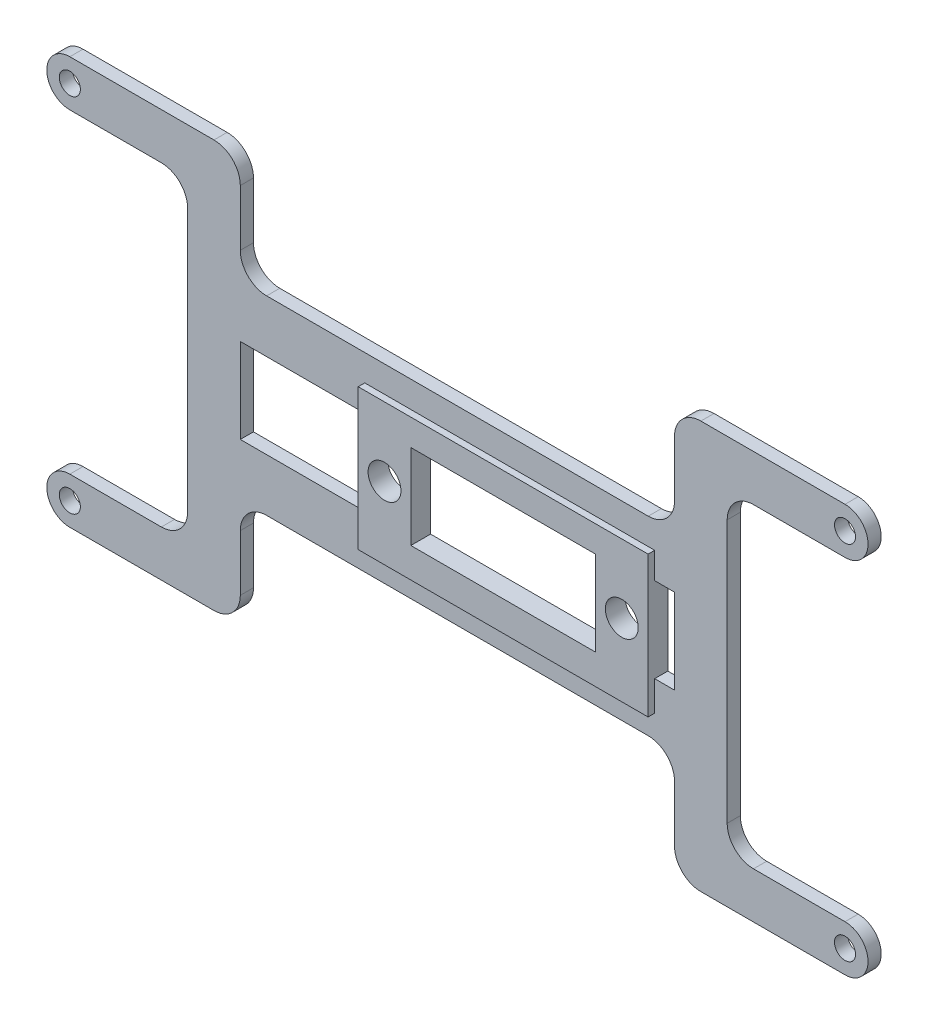
from build123d import *

# Parameters (mm, degrees)
SKETCH1_R            = 1.6
SKETCH1_R_2          = 2.1
BOSS_EXTRUDE3_DEPTH  = 2
BOSS_EXTRUDE4_DEPTH  = 2
SKETCH4_W            = 66
SKETCH4_H            = 16.340111315
SKETCH4_H_2          = 24.741581589
CUT_EXTRUDE3_DEPTH   = 14.5
FILLET1_R            = 4
SKETCH5_W            = 26
SKETCH5_H            = 27
SKETCH5_R            = 6
BOSS_EXTRUDE5_DEPTH  = 2
SKETCH6_W            = 5
SKETCH6_H            = 27
CUT_EXTRUDE4_DEPTH   = 14.5
SKETCH7_R            = 2.5
BOSS_EXTRUDE6_DEPTH  = 2
SKETCH8_R            = 2.5
CUT_EXTRUDE5_DEPTH   = 10
SKETCH9_W            = 22.081
SKETCH9_H            = 27
CUT_EXTRUDE6_DEPTH   = 10
CUT_EXTRUDE7_DEPTH   = 10
SKETCH11_W           = 28.061
SKETCH11_H           = 7.05
BOSS_EXTRUDE7_DEPTH  = 2
SKETCH12_W           = 44.061
SKETCH12_H           = 28.9
CUT_EXTRUDE9_DEPTH   = 10
BOSS_EXTRUDE9_DEPTH  = 2
FILLET2_R            = 4
SKETCH14_R           = 2.5
SKETCH14_W           = 28.061
SKETCH14_H           = 12.9
BOSS_EXTRUDE10_DEPTH = 1


with BuildPart() as part:
    # Sketch1 → Boss-Extrude3 (new body)
    with BuildSketch(Plane.XY):
        with BuildLine():
            Line((0, 3.5), (37.911912125, 3.5))
            Line((37.911912125, 3.5), (37.911912125, 13.97107578))
            Line((37.911912125, 13.97107578), (37.911912125, 40.97107578))
            Line((37.911912125, 40.97107578), (37.911912125, 51.44215156))
            Line((37.911912125, 51.44215156), (0, 51.44215156))
            ThreePointArc((0, 51.44215156), (-3.5, 54.94215156), (0, 58.44215156))
            Line((0, 58.44215156), (45.911912125, 58.44215156))
            Line((45.911912125, 58.44215156), (45.911912125, 51.44215156))
            Line((45.911912125, 51.44215156), (45.911912125, 48.97107578))
            Line((45.911912125, 48.97107578), (50.911912125, 48.97107578))
            Line((50.911912125, 48.97107578), (66.911912125, 48.97107578))
            Line((66.911912125, 48.97107578), (71.911912125, 48.97107578))
            Line((71.911912125, 48.97107578), (71.911912125, 51.44215156))
            Line((71.911912125, 51.44215156), (71.911912125, 58.44215156))
            Line((71.911912125, 58.44215156), (117.82382425, 58.44215156))
            ThreePointArc((117.82382425, 58.44215156), (121.32382425, 54.94215156), (117.82382425, 51.44215156))
            Line((117.82382425, 51.44215156), (79.911912125, 51.44215156))
            Line((79.911912125, 51.44215156), (79.911912125, 40.97107578))
            Line((79.911912125, 40.97107578), (79.911912125, 13.97107578))
            Line((79.911912125, 13.97107578), (79.911912125, 3.5))
            Line((79.911912125, 3.5), (117.82382425, 3.5))
            ThreePointArc((117.82382425, 3.5), (121.32382425, 0), (117.82382425, -3.5))
            Line((117.82382425, -3.5), (71.911912125, -3.5))
            Line((71.911912125, -3.5), (71.911912125, 3.5))
            Line((71.911912125, 3.5), (71.911912125, 5.97107578))
            Line((71.911912125, 5.97107578), (66.911912125, 5.97107578))
            Line((66.911912125, 5.97107578), (50.911912125, 5.97107578))
            Line((50.911912125, 5.97107578), (45.911912125, 5.97107578))
            Line((45.911912125, 5.97107578), (45.911912125, 3.5))
            Line((45.911912125, 3.5), (45.911912125, -3.5))
            Line((45.911912125, -3.5), (0, -3.5))
            ThreePointArc((0, -3.5), (-3.5, 0), (0, 3.5))
        make_face()
        with Locations((0, 54.94215156)):
            Circle(SKETCH1_R, mode=Mode.SUBTRACT)
        with Locations((117.82382425, 54.94215156)):
            Circle(SKETCH1_R, mode=Mode.SUBTRACT)
        with Locations((117.82382425, 0)):
            Circle(SKETCH1_R, mode=Mode.SUBTRACT)
        Circle(SKETCH1_R, mode=Mode.SUBTRACT)
        with Locations((66.911912125, 44.97107578)):
            Circle(SKETCH1_R_2, mode=Mode.SUBTRACT)
        with Locations((66.911912125, 9.97107578)):
            Circle(SKETCH1_R_2, mode=Mode.SUBTRACT)
        with Locations((50.911912125, 9.97107578)):
            Circle(SKETCH1_R_2, mode=Mode.SUBTRACT)
        with Locations((50.911912125, 44.97107578)):
            Circle(SKETCH1_R_2, mode=Mode.SUBTRACT)
        Polygon((66.911912125, 40.97107578), (50.911912125, 40.97107578), (45.911912125, 40.97107578), (45.911912125, 27.47107578), (45.911912125, 13.97107578), (50.911912125, 13.97107578), (66.911912125, 13.97107578), (71.911912125, 13.97107578), (71.911912125, 27.47107578), (71.911912125, 40.97107578), align=None, mode=Mode.SUBTRACT)
    extrude(amount=BOSS_EXTRUDE3_DEPTH)

    # Sketch3 → Boss-Extrude4 (add)
    with BuildSketch(Plane.XY.offset(2)):
        Polygon((71.911912125, 13.97107578), (99.911912125, 13.97107578), (99.911912125, 3.5), (91.911912125, 3.5), (91.911912125, 5.97107578), (71.911912125, 5.97107578), align=None)
        Polygon((91.911912125, 51.44215156), (99.911912125, 51.44215156), (99.911912125, 40.97107578), (71.911912125, 40.97107578), (71.911912125, 48.97107578), (91.911912125, 48.97107578), align=None)
        Polygon((45.911912125, 40.97107578), (17.911912125, 40.97107578), (17.911912125, 51.44215156), (25.911912125, 51.44215156), (25.911912125, 48.97107578), (45.911912125, 48.97107578), align=None)
        Polygon((25.911912125, 3.5), (17.911912125, 3.5), (17.911912125, 13.97107578), (45.911912125, 13.97107578), (45.911912125, 5.97107578), (25.911912125, 5.97107578), align=None)
    extrude(amount=-BOSS_EXTRUDE4_DEPTH)

    # Sketch4 → Cut-Extrude3 (cut)
    with BuildSketch(Plane.XY.offset(2)):
        with Locations((58.911912125, 57.141131438)):
            Rectangle(SKETCH4_W, SKETCH4_H)
        with Locations((58.911912125, -6.399715014)):
            Rectangle(SKETCH4_W, SKETCH4_H_2)
    extrude(amount=-CUT_EXTRUDE3_DEPTH, mode=Mode.SUBTRACT)

    # Fillet1
    fillet1_edges = [part.edges().sort_by_distance(p)[0] for p in [
        (99.911912125, 13.97107578, 1),
        (99.911912125, 3.5, 1),
        (91.911912125, 5.97107578, 1),
        (91.911912125, 48.97107578, 1),
        (99.911912125, 51.44215156, 1),
        (99.911912125, 40.97107578, 1),
        (17.911912125, 40.97107578, 1),
        (17.911912125, 51.44215156, 1),
        (25.911912125, 48.97107578, 1),
        (25.911912125, 5.97107578, 1),
        (17.911912125, 3.5, 1),
        (17.911912125, 13.97107578, 1),
        (91.911912125, 58.44215156, 1),
        (25.911912125, 58.44215156, 1),
        (91.911912125, -3.5, 1),
        (25.911912125, -3.5, 1),
    ]]
    fillet(fillet1_edges, radius=FILLET1_R)

    # Sketch5 → Boss-Extrude5 (add)
    with BuildSketch(Plane.XY.offset(2)):
        with Locations((58.911912125, 27.47107578)):
            Rectangle(SKETCH5_W, SKETCH5_H)
        with Locations((58.911912125, 27.47107578)):
            Circle(SKETCH5_R, mode=Mode.SUBTRACT)
    extrude(amount=-BOSS_EXTRUDE5_DEPTH)

    # Sketch6 → Cut-Extrude4 (cut)
    with BuildSketch(Plane.XY.offset(2)):
        with Locations((40.411912125, 27.47107578)):
            Rectangle(SKETCH6_W, SKETCH6_H)
        with Locations((77.411912125, 27.47107578)):
            Rectangle(SKETCH6_W, SKETCH6_H)
    extrude(amount=-CUT_EXTRUDE4_DEPTH, mode=Mode.SUBTRACT)

    # Sketch7 → Boss-Extrude6 (add)
    with BuildSketch(Plane.XY.offset(2)):
        Polygon((80.891912125, 27.47107578), (80.891912125, 40.97107578), (88.891912125, 40.97107578), (88.891912125, 27.47107578), (88.891912125, 13.97107578), (80.891912125, 13.97107578), align=None)
        with Locations((84.891912125, 27.47107578)):
            Circle(SKETCH7_R, mode=Mode.SUBTRACT)
    extrude(amount=-BOSS_EXTRUDE6_DEPTH)

    # Sketch8 → Cut-Extrude5 (cut)
    with BuildSketch(Plane.XY.offset(2)):
        with Locations((48.830912125, 27.47107578)):
            Circle(SKETCH8_R)
    extrude(amount=-CUT_EXTRUDE5_DEPTH, mode=Mode.SUBTRACT)

    # Sketch9 → Cut-Extrude6 (cut)
    with BuildSketch(Plane.XY.offset(2)):
        Polygon((42.911912125, 40.97107578), (44.830912125, 40.97107578), (44.830912125, 27.47107578), (44.830912125, 13.97107578), (42.911912125, 13.97107578), align=None)
        with Locations((63.871412125, 27.47107578)):
            Rectangle(SKETCH9_W, SKETCH9_H)
    extrude(amount=-CUT_EXTRUDE6_DEPTH, mode=Mode.SUBTRACT)

    # Sketch10 → Cut-Extrude7 (cut)
    with BuildSketch(Plane.XY.offset(2)):
        Polygon((44.830912125, 13.97107578), (44.830912125, 13.02107578), (88.891912125, 13.02107578), (88.891912125, 13.97107578), (106.020559472, 13.97107578), (106.020559472, 3.5), (12.964535502, 3.5), (12.964535502, 13.97107578), align=None)
        Polygon((88.891912125, 40.97107578), (88.891912125, 41.92107578), (44.830912125, 41.92107578), (44.830912125, 40.97107578), (12.964535502, 40.97107578), (12.964535502, 51.44215156), (106.020559472, 51.44215156), (106.020559472, 40.97107578), align=None)
    extrude(amount=-CUT_EXTRUDE7_DEPTH, mode=Mode.SUBTRACT)

    # Sketch11 → Boss-Extrude7 (add)
    with BuildSketch(Plane.XY.offset(2)):
        with Locations((66.861412125, 37.44607578)):
            Rectangle(SKETCH11_W, SKETCH11_H)
        with Locations((66.861412125, 17.49607578)):
            Rectangle(SKETCH11_W, SKETCH11_H)
    extrude(amount=-BOSS_EXTRUDE7_DEPTH)

    # Sketch12 → Cut-Extrude9 (cut)
    with BuildSketch(Plane.XY.offset(2)):
        Polygon((25.911912125, 1.23553789), (25.911912125, 54.44215156), (91.911912125, 54.44215156), (91.911912125, 0.5), align=None)
        with Locations((66.861412125, 27.47107578)):
            Rectangle(SKETCH12_W, SKETCH12_H, mode=Mode.SUBTRACT)
    extrude(amount=-CUT_EXTRUDE9_DEPTH, mode=Mode.SUBTRACT)

    # Sketch13 → Boss-Extrude9 (add)
    with BuildSketch(Plane.XY.offset(2)):
        Polygon((17.911912125, 3.5), (25.911912125, 3.5), (25.911912125, 13.02107578), (44.830912125, 13.02107578), (44.830912125, 21.02107578), (25.911912125, 21.02107578), (25.911912125, 33.92107578), (44.830912125, 33.92107578), (44.830912125, 41.92107578), (25.911912125, 41.92107578), (25.911912125, 51.44215156), (17.911912125, 51.44215156), (17.911912125, 13.02107578), align=None)
        Polygon((99.911912125, 51.44215156), (91.911912125, 51.44215156), (91.911912125, 41.92107578), (88.891912125, 41.92107578), (88.891912125, 33.92107578), (91.911912125, 33.92107578), (91.911912125, 21.02107578), (88.891912125, 21.02107578), (88.891912125, 13.02107578), (91.911912125, 13.02107578), (91.911912125, 3.5), (99.911912125, 3.5), (99.911912125, 41.92107578), align=None)
    extrude(amount=-BOSS_EXTRUDE9_DEPTH)

    # Fillet2
    fillet2_edges = [part.edges().sort_by_distance(p)[0] for p in [
        (99.911912125, 51.44215156, 1),
        (99.911912125, 3.5, 1),
        (91.911912125, 13.02107578, 1),
        (91.911912125, 41.92107578, 1),
        (25.911912125, 13.02107578, 1),
        (17.911912125, 3.5, 1),
        (17.911912125, 51.44215156, 1),
        (25.911912125, 41.92107578, 1),
    ]]
    fillet(fillet2_edges, radius=FILLET2_R)

    # Sketch14 → Boss-Extrude10 (add)
    with BuildSketch(Plane.XY.offset(2)):
        Polygon((44.830912125, 33.92107578), (44.830912125, 37.92107578), (88.891912125, 37.92107578), (88.891912125, 33.92107578), (88.891912125, 21.02107578), (88.891912125, 16.479152283), (44.830912125, 16.479152283), (44.830912125, 21.02107578), align=None)
        with Locations((48.830912125, 27.47107578)):
            Circle(SKETCH14_R, mode=Mode.SUBTRACT)
        with Locations((84.891912125, 27.47107578)):
            Circle(SKETCH14_R, mode=Mode.SUBTRACT)
        with Locations((66.861412125, 27.47107578)):
            Rectangle(SKETCH14_W, SKETCH14_H, mode=Mode.SUBTRACT)
    extrude(amount=BOSS_EXTRUDE10_DEPTH)


solid = part.part
